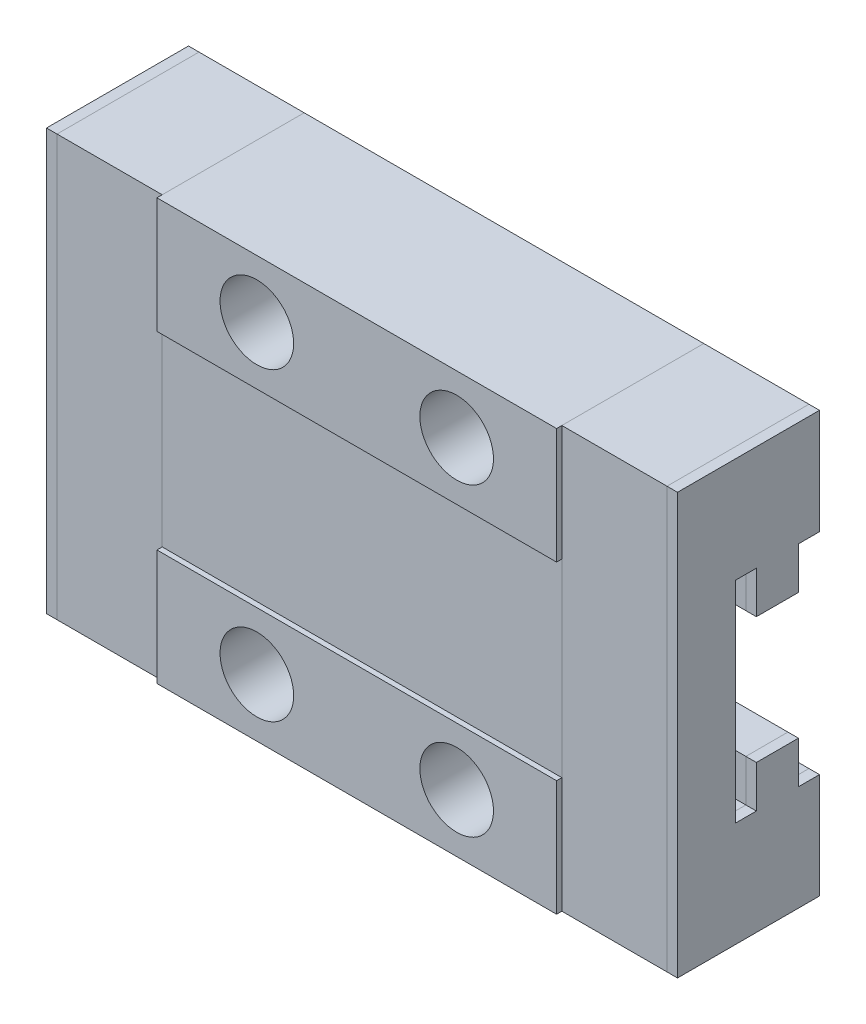
from build123d import *

# Parameters (mm, degrees)
ESQUISSE1_W             = 19
ESQUISSE1_H             = 5.5
ESQUISSE1_R             = 1.75
BOSS_EXTRU_1_DEPTH      = 7
BOSS_EXTRU_1_2_DEPTH    = 7
ESQUISSE1_3_W           = 19
ESQUISSE1_3_H           = 9
BOSS_EXTRU_2_DEPTH      = 6.75
ESQUISSE1_4_W           = 5
ESQUISSE1_4_H           = 20
BOSS_EXTRU_3_DEPTH      = 6.75
BOSS_EXTRU_3_2_DEPTH    = 6.75
ESQUISSE1_5_W           = 0.5
ESQUISSE1_5_H           = 20
BOSS_EXTRU_4_DEPTH      = 6.75
BOSS_EXTRU_4_2_DEPTH    = 6.75
ENL_V_MAT_EXTRU_1_DEPTH = 30
ESQUISSE4_R             = 1.75
BOSS_EXTRU_6_DEPTH      = 2.5


with BuildPart() as part:
    # Esquisse1 → Boss.-Extru.1 (new body)
    with BuildSketch(Plane.XY):
        with Locations((0, 7.25)):
            Rectangle(ESQUISSE1_W, ESQUISSE1_H)
        with Locations((-4.75, 7.25)):
            Circle(ESQUISSE1_R, mode=Mode.SUBTRACT)
        with Locations((4.75, 7.25)):
            Circle(ESQUISSE1_R, mode=Mode.SUBTRACT)
    extrude(amount=BOSS_EXTRU_1_DEPTH)



with BuildPart() as body_2:
    # Esquisse1 → Boss.-Extru.1 2 (new body)
    with BuildSketch(Plane.XY):
        with Locations((0, -7.25)):
            Rectangle(ESQUISSE1_W, ESQUISSE1_H)
        with Locations((-4.75, -7.25)):
            Circle(ESQUISSE1_R, mode=Mode.SUBTRACT)
        with Locations((4.75, -7.25)):
            Circle(ESQUISSE1_R, mode=Mode.SUBTRACT)
    extrude(amount=BOSS_EXTRU_1_2_DEPTH)


with BuildPart() as part_1:
    add(part.part)

    add(body_2.part)  # Boss.-Extru.2 merges body 2
    # Esquisse1_3 → Boss.-Extru.2 (add)
    with BuildSketch(Plane.XY):
        Rectangle(ESQUISSE1_3_W, ESQUISSE1_3_H)
    extrude(amount=BOSS_EXTRU_2_DEPTH)


with BuildPart() as body_2_2:
    # Esquisse1_4 → Boss.-Extru.3 (new body)
    with BuildSketch(Plane.XY):
        with Locations((-12, 0)):
            Rectangle(ESQUISSE1_4_W, ESQUISSE1_4_H)
    extrude(amount=BOSS_EXTRU_3_DEPTH)


with BuildPart() as body_3:
    # Esquisse1_4 → Boss.-Extru.3 2 (new body)
    with BuildSketch(Plane.XY):
        with Locations((12, 0)):
            Rectangle(ESQUISSE1_4_W, ESQUISSE1_4_H)
    extrude(amount=BOSS_EXTRU_3_2_DEPTH)


with BuildPart() as body_4:
    # Esquisse1_5 → Boss.-Extru.4 (new body)
    with BuildSketch(Plane.XY):
        with Locations((-14.75, 0)):
            Rectangle(ESQUISSE1_5_W, ESQUISSE1_5_H)
    extrude(amount=BOSS_EXTRU_4_DEPTH)


with BuildPart() as body_5:
    # Esquisse1_5 → Boss.-Extru.4 2 (new body)
    with BuildSketch(Plane.XY):
        with Locations((14.75, 0)):
            Rectangle(ESQUISSE1_5_W, ESQUISSE1_5_H)
    extrude(amount=BOSS_EXTRU_4_2_DEPTH)


with BuildPart() as enl_v_mat_extru_1_tool:
    # Esquisse2 → Enlèv. mat.-Extru.1 (new body)
    with BuildSketch(Plane.ZY.offset(15)):
        Polygon((3, -5), (4, -5), (4, 5), (3, 5), (3, 3), (1, 3), (1, 5), (0, 5), (0, -5), (1, -5), (1, -3), (3, -3), align=None)
    extrude(amount=-ENL_V_MAT_EXTRU_1_DEPTH)


with BuildPart() as part_2:
    add(part_1.part)

    # Enlèv. mat.-Extru.1: cut by enl_v_mat_extru_1_tool
    add(enl_v_mat_extru_1_tool.part, mode=Mode.SUBTRACT)

    # Esquisse4 → Boss.-Extru.6 (add)
    with BuildSketch(Plane(origin=(0, 0, 0), x_dir=(-1, 0, 0), z_dir=(0, 0, -1))):
        with Locations((-4.75, 7.25)):
            Circle(ESQUISSE4_R)
        with Locations((4.75, 7.25)):
            Circle(ESQUISSE4_R)
        with Locations((4.75, -7.25)):
            Circle(ESQUISSE4_R)
        with Locations((-4.75, -7.25)):
            Circle(ESQUISSE4_R)
    extrude(amount=-BOSS_EXTRU_6_DEPTH)


with BuildPart() as body_2_2_1:
    add(body_2_2.part)

    # Enlèv. mat.-Extru.1: cut by enl_v_mat_extru_1_tool
    add(enl_v_mat_extru_1_tool.part, mode=Mode.SUBTRACT)


with BuildPart() as body_3_1:
    add(body_3.part)

    # Enlèv. mat.-Extru.1: cut by enl_v_mat_extru_1_tool
    add(enl_v_mat_extru_1_tool.part, mode=Mode.SUBTRACT)


with BuildPart() as body_4_1:
    add(body_4.part)

    # Enlèv. mat.-Extru.1: cut by enl_v_mat_extru_1_tool
    add(enl_v_mat_extru_1_tool.part, mode=Mode.SUBTRACT)


with BuildPart() as body_5_1:
    add(body_5.part)

    # Enlèv. mat.-Extru.1: cut by enl_v_mat_extru_1_tool
    add(enl_v_mat_extru_1_tool.part, mode=Mode.SUBTRACT)


solid = Compound([part_2.part, body_2_2_1.part, body_3_1.part, body_4_1.part, body_5_1.part])
